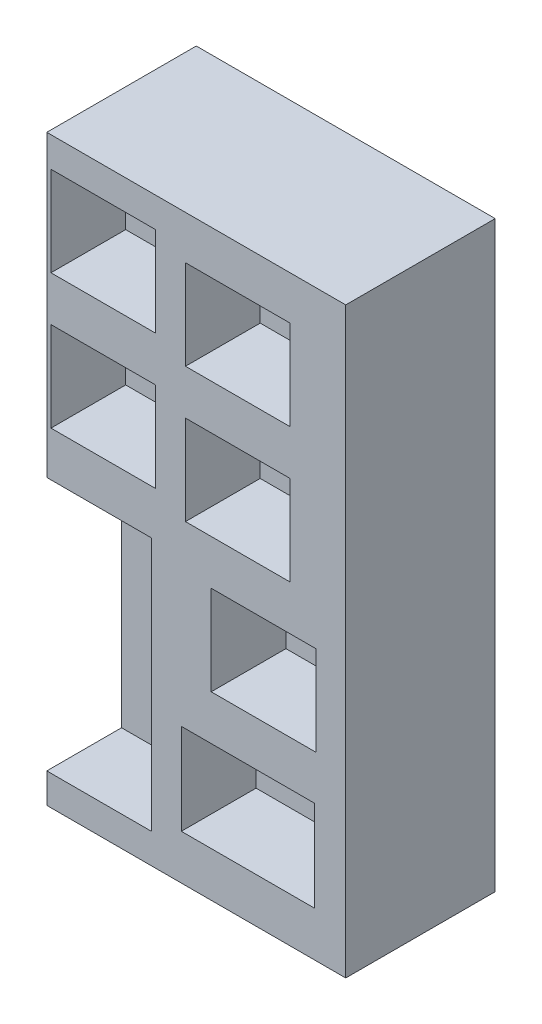
from build123d import *

# Parameters (mm, degrees)
SKETCH1_W           = 25.4
SKETCH1_H           = 49.53
BOSS_EXTRUDE2_DEPTH = 12.7
SKETCH2_W           = 8.89
SKETCH2_H           = 21.59
SKETCH2_W_2         = 11.324200872
SKETCH2_H_2         = 7.724794812
SKETCH2_H_3         = 7.62
CUT_EXTRUDE1_DEPTH  = 6.35


with BuildPart() as part:
    # Sketch1 → Boss-Extrude2 (new body)
    with BuildSketch(Plane.XY):
        with Locations((-15.1641049, 1.570131369)):
            Rectangle(SKETCH1_W, SKETCH1_H)
    extrude(amount=BOSS_EXTRUDE2_DEPTH)

    # Sketch2 → Cut-Extrude1 (cut)
    with BuildSketch(Plane.XY.offset(12.7)):
        with Locations((-23.4191049, -9.859868631)):
            Rectangle(SKETCH2_W, SKETCH2_H)
        with Locations((-10.772004464, -15.522471225)):
            Rectangle(SKETCH2_W_2, SKETCH2_H_2)
        with Locations((-9.4491049, -4.040073819)):
            Rectangle(SKETCH2_W, SKETCH2_H_3)
        with Locations((-23.066267196, 8.555131369)):
            Rectangle(SKETCH2_W, SKETCH2_H_3)
        with Locations((-11.636267196, 7.389926181)):
            Rectangle(SKETCH2_W, SKETCH2_H_3)
        with Locations((-23.066267196, 19.985131369)):
            Rectangle(SKETCH2_W, SKETCH2_H_3)
        with Locations((-11.636267196, 18.819926181)):
            Rectangle(SKETCH2_W, SKETCH2_H_3)
    extrude(amount=-CUT_EXTRUDE1_DEPTH, mode=Mode.SUBTRACT)


solid = part.part
